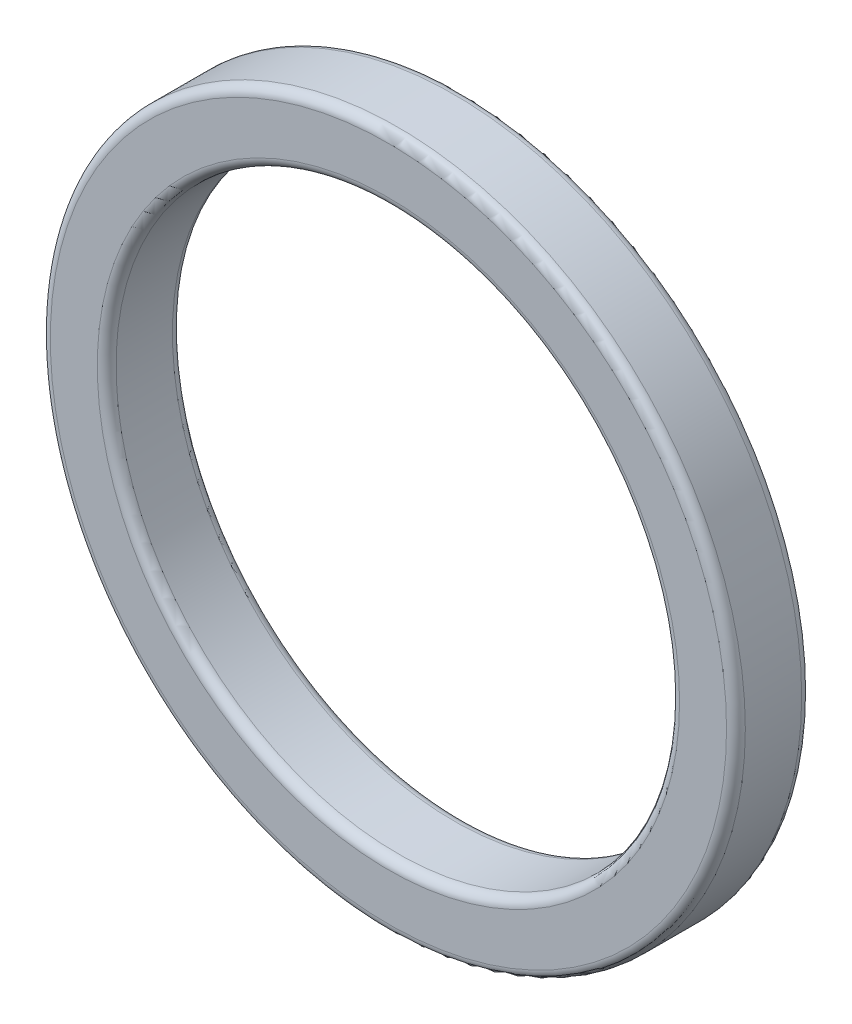
from build123d import *

# Parameters (mm, degrees)
SKETCH_1_R      = 18.5
SKETCH_1_R_2    = 15
EXTRUDE_1_DEPTH = 4
FILLET_1_R      = 0.5


with BuildPart() as part:
    # 草图1 → 凸台-拉伸1 (new body)
    with BuildSketch(Plane.XY):
        Circle(SKETCH_1_R)
        Circle(SKETCH_1_R_2, mode=Mode.SUBTRACT)
    extrude(amount=EXTRUDE_1_DEPTH)

    # 圆角1
    fillet_1_edges = [part.edges().sort_by_distance(p)[0] for p in [
        (-18.5, 0, 0),
        (-18.5, 0, 4),
        (-15, 0, 0),
        (-15, 0, 4),
    ]]
    fillet(fillet_1_edges, radius=FILLET_1_R)


solid = part.part
